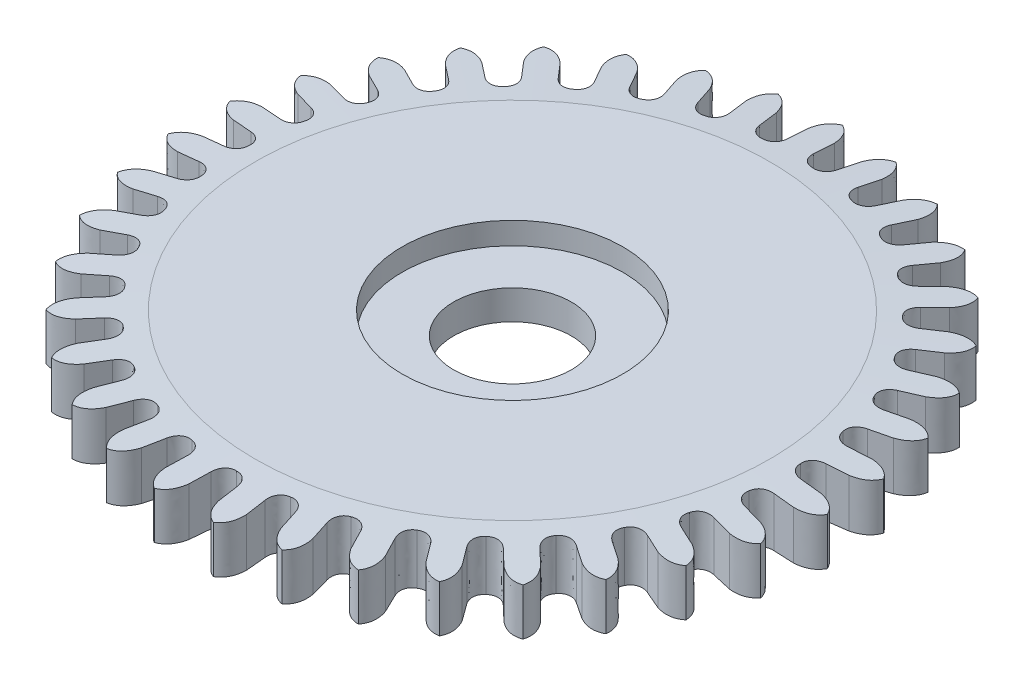
from build123d import *

# Parameters (mm, degrees)
SKETCH1_R                   = 4.485
BOSS_EXTRUDE1_DEPTH         = 0.7
CHAMFER1_SIZE               = 0.0614
CHAMFER1_SIZE2              = 0.985
SKETCH2_OUTSIDE_W           = 13.51
SKETCH2_OUTSIDE_H           = 13.51
CUT_EXTRUDE1_35_TEETH_DEPTH = 0.7
CUT_EXTRUDE2_REACH          = 8.378
SKETCH3_R                   = 0.8
SKETCH4_R                   = 1.5
CUT_EXTRUDE3_DEPTH          = 0.3


with BuildPart() as part:
    # Sketch1 → Boss-Extrude1 (new body)
    with BuildSketch(Plane(origin=(0, 0, 0), x_dir=(1, 0, 0), z_dir=(0, 1, 0))):
        with Locations(Location((0, 0, 0), (0, 0, 270))):
            Circle(SKETCH1_R)
    extrude(amount=BOSS_EXTRUDE1_DEPTH)

    # Chamfer1
    chamfer1_edges = [part.edges().sort_by_distance(p)[0] for p in [
        (0, 0.7, -4.485),
    ]]
    chamfer1_side = [part.faces().sort_by_distance(p)[0] for p in [
        (0, 0.35, -4.485),
    ]]
    chamfer(chamfer1_edges, length=CHAMFER1_SIZE, length2=CHAMFER1_SIZE2, reference=chamfer1_side[0])

    # Sketch2 outside → Cut-Extrude1 (35 teeth) (cut)
    with BuildSketch(Plane(origin=(0, 0, 0), x_dir=(1, 0, 0), z_dir=(0, 1, 0))):
        Rectangle(SKETCH2_OUTSIDE_W, SKETCH2_OUTSIDE_H)
        with BuildLine():
            Line((0.176, 4.199313396), (0.176, 3.919050012))
            add(Edge.make_bspline(
                [(0.176, 3.919050012), (0.17522517, 3.83644485), (0.222147531, 3.741303062), (0.336147408, 3.734903602)],
                knots=[0, 0, 0, 0, 1, 1, 1, 1], degree=3))
            add(Edge.make_bspline(
                [(0.526601793, 3.88749528), (0.51261445, 3.806079265), (0.449457929, 3.720844756), (0.336147408, 3.734903602)],
                knots=[0, 0, 0, 0, 1, 1, 1, 1], degree=3))
            Line((0.526601793, 3.88749528), (0.576644753, 4.163254716))
            add(Edge.make_bspline(
                [(0.800827673, 4.412924204), (0.637500689, 4.367124725), (0.576644753, 4.163254716)],
                knots=[0, 0, 0, 1, 1, 1], degree=2))
            add(Edge.make_bspline(
                [(0.800827673, 4.412924204), (0.937647307, 4.312656144), (0.922987968, 4.100402689)],
                knots=[0, 0, 0, 1, 1, 1], degree=2))
            Line((0.922987968, 4.100402689), (0.872945008, 3.824643253))
            add(Edge.make_bspline(
                [(0.872945008, 3.824643253), (0.857432909, 3.743503941), (0.886612986, 3.64151281), (0.997638171, 3.614860728)],
                knots=[0, 0, 0, 0, 1, 1, 1, 1], degree=3))
            add(Edge.make_bspline(
                [(1.212278171, 3.73099325), (1.18397822, 3.653383161), (1.106617441, 3.580795438), (0.997638171, 3.614860728)],
                knots=[0, 0, 0, 0, 1, 1, 1, 1], degree=3))
            Line((1.212278171, 3.73099325), (1.310755669, 3.993385603))
            add(Edge.make_bspline(
                [(1.575916086, 4.199013394), (1.407036021, 4.18311309), (1.310755669, 3.993385603)],
                knots=[0, 0, 0, 1, 1, 1], degree=2))
            add(Edge.make_bspline(
                [(1.575916086, 4.199013394), (1.692633418, 4.075926594), (1.640310343, 3.869701665)],
                knots=[0, 0, 0, 1, 1, 1], degree=2))
            Line((1.640310343, 3.869701665), (1.541832846, 3.607309312))
            add(Edge.make_bspline(
                [(1.541832846, 3.607309312), (1.512082049, 3.530243735), (1.52258197, 3.424681339), (1.627064022, 3.378633255)],
                knots=[0, 0, 0, 0, 1, 1, 1, 1], degree=3))
            add(Edge.make_bspline(
                [(1.858990932, 3.454574028), (1.817287955, 3.383264317), (1.728209357, 3.325656409), (1.627064022, 3.378633255)],
                knots=[0, 0, 0, 0, 1, 1, 1, 1], degree=3))
            Line((1.858990932, 3.454574028), (2.002737819, 3.695165792))
            add(Edge.make_bspline(
                [(2.300353259, 3.850142838), (2.131348057, 3.864652759), (2.002737819, 3.695165792)],
                knots=[0, 0, 0, 1, 1, 1], degree=2))
            add(Edge.make_bspline(
                [(2.300353259, 3.850142838), (2.393216899, 3.70819341), (2.304911794, 3.514625246)],
                knots=[0, 0, 0, 1, 1, 1], degree=2))
            Line((2.304911794, 3.514625246), (2.161164907, 3.274033482))
            add(Edge.make_bspline(
                [(2.161164907, 3.274033482), (2.118131628, 3.20351859), (2.109613917, 3.097777792), (2.204194696, 3.033813729)],
                knots=[0, 0, 0, 0, 1, 1, 1, 1], degree=3))
            add(Edge.make_bspline(
                [(2.445954194, 3.067121954), (2.392188561, 3.004404573), (2.294255204, 2.963628045), (2.204194696, 3.033813729)],
                knots=[0, 0, 0, 0, 1, 1, 1, 1], degree=3))
            Line((2.445954194, 3.067121954), (2.630350328, 3.278180311))
            add(Edge.make_bspline(
                [(2.950855185, 3.377525524), (2.787156813, 3.421979309), (2.630350328, 3.278180311)],
                knots=[0, 0, 0, 1, 1, 1], degree=2))
            add(Edge.make_bspline(
                [(2.950855185, 3.377525524), (3.016880419, 3.221275838), (2.895431484, 3.04658588)],
                knots=[0, 0, 0, 1, 1, 1], degree=2))
            Line((2.895431484, 3.04658588), (2.71103535, 2.835527522))
            add(Edge.make_bspline(
                [(2.71103535, 2.835527522), (2.656102713, 2.773829722), (2.628841137, 2.671309119), (2.710480739, 2.591484934)],
                knots=[0, 0, 0, 0, 1, 1, 1, 1], degree=3))
            add(Edge.make_bspline(
                [(2.954302476, 2.581090057), (2.890202258, 2.528980794), (2.7865618, 2.506346238), (2.710480739, 2.591484934)],
                knots=[0, 0, 0, 0, 1, 1, 1, 1], degree=3))
            Line((2.954302476, 2.581090057), (3.173421213, 2.755831418))
            add(Edge.make_bspline(
                [(3.506514198, 2.796351761), (3.353384056, 2.869320627), (3.173421213, 2.755831418)],
                knots=[0, 0, 0, 1, 1, 1], degree=2))
            add(Edge.make_bspline(
                [(3.506514198, 2.796351761), (3.543578921, 2.630823811), (3.392889623, 2.480626736)],
                knots=[0, 0, 0, 1, 1, 1], degree=2))
            Line((3.392889623, 2.480626736), (3.173770886, 2.305885375))
            add(Edge.make_bspline(
                [(3.173770886, 2.305885375), (3.108704471, 2.254987685), (3.06357524, 2.158982372), (3.129649701, 2.06586368)],
                knots=[0, 0, 0, 0, 1, 1, 1, 1], degree=3))
            add(Edge.make_bspline(
                [(3.367697045, 2.012099801), (3.295322476, 1.972273492), (3.189306007, 1.968508401), (3.129649701, 2.06586368)],
                knots=[0, 0, 0, 0, 1, 1, 1, 1], degree=3))
            Line((3.367697045, 2.012099801), (3.614495729, 2.144907836))
            add(Edge.make_bspline(
                [(3.949470959, 2.125300951), (3.811830776, 2.22443962), (3.614495729, 2.144907836)],
                knots=[0, 0, 0, 1, 1, 1], degree=2))
            add(Edge.make_bspline(
                [(3.949470959, 2.125300951), (3.95638388, 1.955814941), (3.781297498, 1.834938209)],
                knots=[0, 0, 0, 1, 1, 1], degree=2))
            Line((3.781297498, 1.834938209), (3.534498815, 1.702130174))
            add(Edge.make_bspline(
                [(3.534498815, 1.702130174), (3.46138991, 1.663668488), (3.399843513, 1.577264155), (3.448229147, 1.473843869)],
                knots=[0, 0, 0, 0, 1, 1, 1, 1], degree=3))
            add(Edge.make_bspline(
                [(3.672851061, 1.378439003), (3.594528319, 1.352175697), (3.489543295, 1.367401084), (3.448229147, 1.473843869)],
                knots=[0, 0, 0, 0, 1, 1, 1, 1], degree=3))
            Line((3.672851061, 1.378439003), (3.939397378, 1.465045151))
            add(Edge.make_bspline(
                [(4.265488474, 1.385941219), (4.147762119, 1.508063294), (3.939397378, 1.465045151)],
                knots=[0, 0, 0, 1, 1, 1], degree=2))
            add(Edge.make_bspline(
                [(4.265488474, 1.385941219), (4.242027406, 1.21794457), (4.04817136, 1.130273257)],
                knots=[0, 0, 0, 1, 1, 1], degree=2))
            Line((4.04817136, 1.130273257), (3.781625043, 1.043667109))
            add(Edge.make_bspline(
                [(3.781625043, 1.043667109), (3.70282343, 1.018877617), (3.626838019, 0.944851371), (3.655979671, 0.834453502)],
                knots=[0, 0, 0, 0, 1, 1, 1, 1], degree=3))
            add(Edge.make_bspline(
                [(3.859956621, 0.70047404), (3.778203063, 0.688617862), (3.67762379, 0.722344371), (3.655979671, 0.834453502)],
                knots=[0, 0, 0, 0, 1, 1, 1, 1], degree=3))
            Line((3.859956621, 0.70047404), (4.137683555, 0.738094709))
            add(Edge.make_bspline(
                [(4.44440968, 0.602036197), (4.350380974, 0.743216572), (4.137683555, 0.738094709)],
                knots=[0, 0, 0, 1, 1, 1], degree=2))
            add(Edge.make_bspline(
                [(4.44440968, 0.602036197), (4.391328681, 0.440928459), (4.184933664, 0.389280393)],
                knots=[0, 0, 0, 1, 1, 1], degree=2))
            Line((4.184933664, 0.389280393), (3.907206731, 0.351659724))
            add(Edge.make_bspline(
                [(3.907206731, 0.351659724), (3.825245157, 0.34133918), (3.737262967, 0.282070286), (3.746224, 0.168243114)],
                knots=[0, 0, 0, 0, 1, 1, 1, 1], degree=3))
            add(Edge.make_bspline(
                [(3.923, -4.734e-06), (3.840443253, 0.002927283), (3.747502431, 0.054070916), (3.746224, 0.168243114)],
                knots=[0, 0, 0, 0, 1, 1, 1, 1], degree=3))
            Line((3.923, -4.734e-06), (4.202981177, -0.012578703))
            add(Edge.make_bspline(
                [(4.480483902, -0.201218764), (4.413175005, -0.045517742), (4.202981177, -0.012578703)],
                knots=[0, 0, 0, 1, 1, 1], degree=2))
            add(Edge.make_bspline(
                [(4.480483902, -0.201218764), (4.399489039, -0.350259456), (4.187188757, -0.364224263)],
                knots=[0, 0, 0, 1, 1, 1], degree=2))
            Line((4.187188757, -0.364224263), (3.90720758, -0.351650294))
            add(Edge.make_bspline(
                [(3.90720758, -0.351650294), (3.824720358, -0.347170178), (3.727569208, -0.38977677), (3.716061607, -0.503374747)],
                knots=[0, 0, 0, 0, 1, 1, 1, 1], degree=3))
            add(Edge.make_bspline(
                [(3.859954931, -0.700483356), (3.779248437, -0.682857382), (3.69693326, -0.615940423), (3.716061607, -0.503374747)],
                knots=[0, 0, 0, 0, 1, 1, 1, 1], degree=3))
            Line((3.859954931, -0.700483356), (4.133191526, -0.762847826))
            add(Edge.make_bspline(
                [(4.372551685, -0.998006389), (4.33412596, -0.832789078), (4.133191526, -0.762847826)],
                knots=[0, 0, 0, 1, 1, 1], degree=2))
            add(Edge.make_bspline(
                [(4.372551685, -0.998006389), (4.266246199, -1.130189744), (4.054864158, -1.106022451)],
                knots=[0, 0, 0, 1, 1, 1], degree=2))
            Line((4.054864158, -1.106022451), (3.781627562, -1.043657982))
            add(Edge.make_bspline(
                [(3.781627562, -1.043657982), (3.701265899, -1.024521201), (3.598068307, -1.04909608), (3.566461936, -1.158813729)],
                knots=[0, 0, 0, 0, 1, 1, 1, 1], degree=3))
            add(Edge.make_bspline(
                [(3.672847734, -1.378447867), (3.596585466, -1.346694448), (3.527541612, -1.26615493), (3.566461936, -1.158813729)],
                knots=[0, 0, 0, 0, 1, 1, 1, 1], degree=3))
            Line((3.672847734, -1.378447867), (3.930557699, -1.488598392))
            add(Edge.make_bspline(
                [(4.124082059, -1.762717266), (4.115774541, -1.593293888), (3.930557699, -1.488598392)],
                knots=[0, 0, 0, 1, 1, 1], degree=2))
            add(Edge.make_bspline(
                [(4.124082059, -1.762717266), (3.995882696, -1.873794804), (3.792212888, -1.812272168)],
                knots=[0, 0, 0, 1, 1, 1], degree=2))
            Line((3.792212888, -1.812272168), (3.534502923, -1.702121643))
            add(Edge.make_bspline(
                [(3.534502923, -1.702121643), (3.458849709, -1.668943269), (3.352922531, -1.674696579), (3.302233244, -1.777007484)],
                knots=[0, 0, 0, 0, 1, 1, 1, 1], degree=3))
            add(Edge.make_bspline(
                [(3.367692189, -2.012107929), (3.298325279, -1.967247647), (3.244771874, -1.875674176), (3.302233244, -1.777007484)],
                knots=[0, 0, 0, 0, 1, 1, 1, 1], degree=3))
            Line((3.367692189, -2.012107929), (3.601592513, -2.166504181))
            add(Edge.make_bspline(
                [(3.743061042, -2.470772961), (3.765138742, -2.302588922), (3.601592513, -2.166504181)],
                knots=[0, 0, 0, 1, 1, 1], degree=2))
            add(Edge.make_bspline(
                [(3.743061042, -2.470772961), (3.597088236, -2.557174557), (3.407676776, -2.460273967)],
                knots=[0, 0, 0, 1, 1, 1], degree=2))
            Line((3.407676776, -2.460273967), (3.173776452, -2.305877715))
            add(Edge.make_bspline(
                [(3.173776452, -2.305877715), (3.105263244, -2.259724128), (3.000011066, -2.246470951), (2.931868059, -2.338086757)],
                knots=[0, 0, 0, 0, 1, 1, 1, 1], degree=3))
            add(Edge.make_bspline(
                [(2.954296246, -2.581097187), (2.894054204, -2.524571888), (2.857712499, -2.424907711), (2.931868059, -2.338086757)],
                knots=[0, 0, 0, 0, 1, 1, 1, 1], degree=3))
            Line((2.954296246, -2.581097187), (3.156869181, -2.774776743))
            add(Edge.make_bspline(
                [(3.241734963, -3.09941598), (3.293488285, -2.937876853), (3.156869181, -2.774776743)],
                knots=[0, 0, 0, 1, 1, 1], degree=2))
            add(Edge.make_bspline(
                [(3.241734963, -3.09941598), (3.0826804, -3.158364615), (2.913615128, -3.029200535)],
                knots=[0, 0, 0, 1, 1, 1], degree=2))
            Line((2.913615128, -3.029200535), (2.711042194, -2.835520979))
            add(Edge.make_bspline(
                [(2.711042194, -2.835520979), (2.651871063, -2.777875594), (2.550676776, -2.746041899), (2.467270222, -2.824017998)],
                knots=[0, 0, 0, 0, 1, 1, 1, 1], degree=3))
            add(Edge.make_bspline(
                [(2.445946791, -3.067127857), (2.396765845, -3.000754311), (2.378803892, -2.896202716), (2.467270222, -2.824017998)],
                knots=[0, 0, 0, 0, 1, 1, 1, 1], degree=3))
            Line((2.445946791, -3.067127857), (2.610681475, -3.293865698))
            add(Edge.make_bspline(
                [(2.636216856, -3.628441219), (2.715982406, -3.478739005), (2.610681475, -3.293865698)],
                knots=[0, 0, 0, 1, 1, 1], degree=2))
            add(Edge.make_bspline(
                [(2.636216856, -3.628441219), (2.469192679, -3.658042236), (2.325907493, -3.500766107)],
                knots=[0, 0, 0, 1, 1, 1], degree=2))
            Line((2.325907493, -3.500766107), (2.161172809, -3.274028266))
            add(Edge.make_bspline(
                [(2.161172809, -3.274028266), (2.113245563, -3.206743853), (2.019361637, -3.157352801), (1.92337229, -3.219182976)],
                knots=[0, 0, 0, 0, 1, 1, 1, 1], degree=3))
            add(Edge.make_bspline(
                [(1.858982594, -3.454578515), (1.82244346, -3.380490021), (1.823438571, -3.274411383), (1.92337229, -3.219182976)],
                knots=[0, 0, 0, 0, 1, 1, 1, 1], degree=3))
            Line((1.858982594, -3.454578515), (1.980584319, -3.707087098))
            add(Edge.make_bspline(
                [(1.945968569, -4.040845371), (2.051182617, -3.907791622), (1.980584319, -3.707087098)],
                knots=[0, 0, 0, 1, 1, 1], degree=2))
            add(Edge.make_bspline(
                [(1.945968569, -4.040845371), (1.776343074, -4.04014737), (1.663443277, -3.859814175)],
                knots=[0, 0, 0, 1, 1, 1], degree=2))
            Line((1.663443277, -3.859814175), (1.541841552, -3.607305591))
            add(Edge.make_bspline(
                [(1.541841552, -3.607305591), (1.506698613, -3.532544726), (1.423142553, -3.467183786), (1.31765559, -3.510880765)],
                knots=[0, 0, 0, 0, 1, 1, 1, 1], degree=3))
            add(Edge.make_bspline(
                [(1.212269166, -3.730996176), (1.189546243, -3.651574001), (1.209466434, -3.547377774), (1.31765559, -3.510880765)],
                knots=[0, 0, 0, 0, 1, 1, 1, 1], degree=3))
            Line((1.212269166, -3.730996176), (1.286829553, -4.001159669))
            add(Edge.make_bspline(
                [(1.193175252, -4.323373429), (1.32045613, -4.211244602), (1.286829553, -4.001159669)],
                knots=[0, 0, 0, 1, 1, 1], degree=2))
            add(Edge.make_bspline(
                [(1.193175252, -4.323373429), (1.026400341, -4.292398843), (0.947514626, -4.094804639)],
                knots=[0, 0, 0, 1, 1, 1], degree=2))
            Line((0.947514626, -4.094804639), (0.872954239, -3.824641146))
            add(Edge.make_bspline(
                [(0.872954239, -3.824641146), (0.85172513, -3.744806704), (0.781182496, -3.665576631), (0.669588355, -3.689735957)],
                knots=[0, 0, 0, 0, 1, 1, 1, 1], degree=3))
            add(Edge.make_bspline(
                [(0.52659241, -3.887496551), (0.51841603, -3.805293388), (0.556621051, -3.706328525), (0.669588355, -3.689735957)],
                knots=[0, 0, 0, 0, 1, 1, 1, 1], degree=3))
            Line((0.52659241, -3.887496551), (0.551715026, -4.166631677))
            add(Edge.make_bspline(
                [(0.4020323, -4.466944707), (0.547289098, -4.379344715), (0.551715026, -4.166631677)],
                knots=[0, 0, 0, 1, 1, 1], degree=2))
            add(Edge.make_bspline(
                [(0.4020323, -4.466944707), (0.243468257, -4.406689086), (0.201132075, -4.198184713)],
                knots=[0, 0, 0, 1, 1, 1], degree=2))
            Line((0.201132075, -4.198184713), (0.176009459, -3.919049588))
            add(Edge.make_bspline(
                [(0.176009459, -3.919049588), (0.1693765, -3.836707514), (0.114114591, -3.746154827), (0, -3.75)],
                knots=[0, 0, 0, 0, 1, 1, 1, 1], degree=3))
            add(Edge.make_bspline(
                [(-0.176009459, -3.919049588), (-0.1693765, -3.836707514), (-0.114114591, -3.746154827), (0, -3.75)],
                knots=[0, 0, 0, 0, 1, 1, 1, 1], degree=3))
            Line((-0.176009459, -3.919049588), (-0.201132075, -4.198184713))
            add(Edge.make_bspline(
                [(-0.4020323, -4.466944707), (-0.243468257, -4.406689086), (-0.201132075, -4.198184713)],
                knots=[0, 0, 0, 1, 1, 1], degree=2))
            add(Edge.make_bspline(
                [(-0.4020323, -4.466944707), (-0.547289098, -4.379344715), (-0.551715026, -4.166631677)],
                knots=[0, 0, 0, 1, 1, 1], degree=2))
            Line((-0.551715026, -4.166631677), (-0.52659241, -3.887496551))
            add(Edge.make_bspline(
                [(-0.52659241, -3.887496551), (-0.51841603, -3.805293388), (-0.556621051, -3.706328525), (-0.669588355, -3.689735957)],
                knots=[0, 0, 0, 0, 1, 1, 1, 1], degree=3))
            add(Edge.make_bspline(
                [(-0.872954239, -3.824641146), (-0.85172513, -3.744806704), (-0.781182496, -3.665576631), (-0.669588355, -3.689735957)],
                knots=[0, 0, 0, 0, 1, 1, 1, 1], degree=3))
            Line((-0.872954239, -3.824641146), (-0.947514626, -4.094804639))
            add(Edge.make_bspline(
                [(-1.193175252, -4.323373429), (-1.026400341, -4.292398843), (-0.947514626, -4.094804639)],
                knots=[0, 0, 0, 1, 1, 1], degree=2))
            add(Edge.make_bspline(
                [(-1.193175252, -4.323373429), (-1.32045613, -4.211244602), (-1.286829553, -4.001159669)],
                knots=[0, 0, 0, 1, 1, 1], degree=2))
            Line((-1.286829553, -4.001159669), (-1.212269166, -3.730996176))
            add(Edge.make_bspline(
                [(-1.212269166, -3.730996176), (-1.189546243, -3.651574001), (-1.209466434, -3.547377774), (-1.31765559, -3.510880765)],
                knots=[0, 0, 0, 0, 1, 1, 1, 1], degree=3))
            add(Edge.make_bspline(
                [(-1.541841552, -3.607305591), (-1.506698613, -3.532544726), (-1.423142553, -3.467183786), (-1.31765559, -3.510880765)],
                knots=[0, 0, 0, 0, 1, 1, 1, 1], degree=3))
            Line((-1.541841552, -3.607305591), (-1.663443277, -3.859814175))
            add(Edge.make_bspline(
                [(-1.945968569, -4.040845371), (-1.776343074, -4.04014737), (-1.663443277, -3.859814175)],
                knots=[0, 0, 0, 1, 1, 1], degree=2))
            add(Edge.make_bspline(
                [(-1.945968569, -4.040845371), (-2.051182617, -3.907791622), (-1.980584319, -3.707087098)],
                knots=[0, 0, 0, 1, 1, 1], degree=2))
            Line((-1.980584319, -3.707087098), (-1.858982594, -3.454578515))
            add(Edge.make_bspline(
                [(-1.858982594, -3.454578515), (-1.82244346, -3.380490021), (-1.823438571, -3.274411383), (-1.92337229, -3.219182976)],
                knots=[0, 0, 0, 0, 1, 1, 1, 1], degree=3))
            add(Edge.make_bspline(
                [(-2.161172809, -3.274028266), (-2.113245563, -3.206743853), (-2.019361637, -3.157352801), (-1.92337229, -3.219182976)],
                knots=[0, 0, 0, 0, 1, 1, 1, 1], degree=3))
            Line((-2.161172809, -3.274028266), (-2.325907493, -3.500766107))
            add(Edge.make_bspline(
                [(-2.636216856, -3.628441219), (-2.469192679, -3.658042236), (-2.325907493, -3.500766107)],
                knots=[0, 0, 0, 1, 1, 1], degree=2))
            add(Edge.make_bspline(
                [(-2.636216856, -3.628441219), (-2.715982406, -3.478739005), (-2.610681475, -3.293865698)],
                knots=[0, 0, 0, 1, 1, 1], degree=2))
            Line((-2.610681475, -3.293865698), (-2.445946791, -3.067127857))
            add(Edge.make_bspline(
                [(-2.445946791, -3.067127857), (-2.396765845, -3.000754311), (-2.378803892, -2.896202716), (-2.467270222, -2.824017998)],
                knots=[0, 0, 0, 0, 1, 1, 1, 1], degree=3))
            add(Edge.make_bspline(
                [(-2.711042194, -2.835520979), (-2.651871063, -2.777875594), (-2.550676776, -2.746041899), (-2.467270222, -2.824017998)],
                knots=[0, 0, 0, 0, 1, 1, 1, 1], degree=3))
            Line((-2.711042194, -2.835520979), (-2.913615128, -3.029200535))
            add(Edge.make_bspline(
                [(-3.241734963, -3.09941598), (-3.0826804, -3.158364615), (-2.913615128, -3.029200535)],
                knots=[0, 0, 0, 1, 1, 1], degree=2))
            add(Edge.make_bspline(
                [(-3.241734963, -3.09941598), (-3.293488285, -2.937876853), (-3.156869181, -2.774776743)],
                knots=[0, 0, 0, 1, 1, 1], degree=2))
            Line((-3.156869181, -2.774776743), (-2.954296246, -2.581097187))
            add(Edge.make_bspline(
                [(-2.954296246, -2.581097187), (-2.894054204, -2.524571888), (-2.857712499, -2.424907711), (-2.931868059, -2.338086757)],
                knots=[0, 0, 0, 0, 1, 1, 1, 1], degree=3))
            add(Edge.make_bspline(
                [(-3.173776452, -2.305877715), (-3.105263244, -2.259724128), (-3.000011066, -2.246470951), (-2.931868059, -2.338086757)],
                knots=[0, 0, 0, 0, 1, 1, 1, 1], degree=3))
            Line((-3.173776452, -2.305877715), (-3.407676776, -2.460273967))
            add(Edge.make_bspline(
                [(-3.743061042, -2.470772961), (-3.597088236, -2.557174557), (-3.407676776, -2.460273967)],
                knots=[0, 0, 0, 1, 1, 1], degree=2))
            add(Edge.make_bspline(
                [(-3.743061042, -2.470772961), (-3.765138742, -2.302588922), (-3.601592513, -2.166504181)],
                knots=[0, 0, 0, 1, 1, 1], degree=2))
            Line((-3.601592513, -2.166504181), (-3.367692189, -2.012107929))
            add(Edge.make_bspline(
                [(-3.367692189, -2.012107929), (-3.298325279, -1.967247647), (-3.244771874, -1.875674176), (-3.302233244, -1.777007484)],
                knots=[0, 0, 0, 0, 1, 1, 1, 1], degree=3))
            add(Edge.make_bspline(
                [(-3.534502923, -1.702121643), (-3.458849709, -1.668943269), (-3.352922531, -1.674696579), (-3.302233244, -1.777007484)],
                knots=[0, 0, 0, 0, 1, 1, 1, 1], degree=3))
            Line((-3.534502923, -1.702121643), (-3.792212888, -1.812272168))
            add(Edge.make_bspline(
                [(-4.124082059, -1.762717266), (-3.995882696, -1.873794804), (-3.792212888, -1.812272168)],
                knots=[0, 0, 0, 1, 1, 1], degree=2))
            add(Edge.make_bspline(
                [(-4.124082059, -1.762717266), (-4.115774541, -1.593293888), (-3.930557699, -1.488598392)],
                knots=[0, 0, 0, 1, 1, 1], degree=2))
            Line((-3.930557699, -1.488598392), (-3.672847734, -1.378447867))
            add(Edge.make_bspline(
                [(-3.672847734, -1.378447867), (-3.596585466, -1.346694448), (-3.527541612, -1.26615493), (-3.566461936, -1.158813729)],
                knots=[0, 0, 0, 0, 1, 1, 1, 1], degree=3))
            add(Edge.make_bspline(
                [(-3.781627562, -1.043657982), (-3.701265899, -1.024521201), (-3.598068307, -1.04909608), (-3.566461936, -1.158813729)],
                knots=[0, 0, 0, 0, 1, 1, 1, 1], degree=3))
            Line((-3.781627562, -1.043657982), (-4.054864158, -1.106022451))
            add(Edge.make_bspline(
                [(-4.372551685, -0.998006389), (-4.266246199, -1.130189744), (-4.054864158, -1.106022451)],
                knots=[0, 0, 0, 1, 1, 1], degree=2))
            add(Edge.make_bspline(
                [(-4.372551685, -0.998006389), (-4.33412596, -0.832789078), (-4.133191526, -0.762847826)],
                knots=[0, 0, 0, 1, 1, 1], degree=2))
            Line((-4.133191526, -0.762847826), (-3.859954931, -0.700483356))
            add(Edge.make_bspline(
                [(-3.859954931, -0.700483356), (-3.779248437, -0.682857382), (-3.69693326, -0.615940423), (-3.716061607, -0.503374747)],
                knots=[0, 0, 0, 0, 1, 1, 1, 1], degree=3))
            add(Edge.make_bspline(
                [(-3.90720758, -0.351650294), (-3.824720358, -0.347170178), (-3.727569208, -0.38977677), (-3.716061607, -0.503374747)],
                knots=[0, 0, 0, 0, 1, 1, 1, 1], degree=3))
            Line((-3.90720758, -0.351650294), (-4.187188757, -0.364224263))
            add(Edge.make_bspline(
                [(-4.480483902, -0.201218764), (-4.399489039, -0.350259456), (-4.187188757, -0.364224263)],
                knots=[0, 0, 0, 1, 1, 1], degree=2))
            add(Edge.make_bspline(
                [(-4.480483902, -0.201218764), (-4.413175005, -0.045517742), (-4.202981177, -0.012578703)],
                knots=[0, 0, 0, 1, 1, 1], degree=2))
            Line((-4.202981177, -0.012578703), (-3.923, -4.734e-06))
            add(Edge.make_bspline(
                [(-3.923, -4.734e-06), (-3.840443253, 0.002927283), (-3.747502431, 0.054070916), (-3.746224, 0.168243114)],
                knots=[0, 0, 0, 0, 1, 1, 1, 1], degree=3))
            add(Edge.make_bspline(
                [(-3.907206731, 0.351659724), (-3.825245157, 0.34133918), (-3.737262967, 0.282070286), (-3.746224, 0.168243114)],
                knots=[0, 0, 0, 0, 1, 1, 1, 1], degree=3))
            Line((-3.907206731, 0.351659724), (-4.184933664, 0.389280393))
            add(Edge.make_bspline(
                [(-4.44440968, 0.602036197), (-4.391328681, 0.440928459), (-4.184933664, 0.389280393)],
                knots=[0, 0, 0, 1, 1, 1], degree=2))
            add(Edge.make_bspline(
                [(-4.44440968, 0.602036197), (-4.350380974, 0.743216572), (-4.137683555, 0.738094709)],
                knots=[0, 0, 0, 1, 1, 1], degree=2))
            Line((-4.137683555, 0.738094709), (-3.859956621, 0.70047404))
            add(Edge.make_bspline(
                [(-3.859956621, 0.70047404), (-3.778203063, 0.688617862), (-3.67762379, 0.722344371), (-3.655979671, 0.834453502)],
                knots=[0, 0, 0, 0, 1, 1, 1, 1], degree=3))
            add(Edge.make_bspline(
                [(-3.781625043, 1.043667109), (-3.70282343, 1.018877617), (-3.626838019, 0.944851371), (-3.655979671, 0.834453502)],
                knots=[0, 0, 0, 0, 1, 1, 1, 1], degree=3))
            Line((-3.781625043, 1.043667109), (-4.04817136, 1.130273257))
            add(Edge.make_bspline(
                [(-4.265488474, 1.385941219), (-4.242027406, 1.21794457), (-4.04817136, 1.130273257)],
                knots=[0, 0, 0, 1, 1, 1], degree=2))
            add(Edge.make_bspline(
                [(-4.265488474, 1.385941219), (-4.147762119, 1.508063294), (-3.939397378, 1.465045151)],
                knots=[0, 0, 0, 1, 1, 1], degree=2))
            Line((-3.939397378, 1.465045151), (-3.672851061, 1.378439003))
            add(Edge.make_bspline(
                [(-3.672851061, 1.378439003), (-3.594528319, 1.352175697), (-3.489543295, 1.367401084), (-3.448229147, 1.473843869)],
                knots=[0, 0, 0, 0, 1, 1, 1, 1], degree=3))
            add(Edge.make_bspline(
                [(-3.534498815, 1.702130174), (-3.46138991, 1.663668488), (-3.399843513, 1.577264155), (-3.448229147, 1.473843869)],
                knots=[0, 0, 0, 0, 1, 1, 1, 1], degree=3))
            Line((-3.534498815, 1.702130174), (-3.781297498, 1.834938209))
            add(Edge.make_bspline(
                [(-3.949470959, 2.125300951), (-3.95638388, 1.955814941), (-3.781297498, 1.834938209)],
                knots=[0, 0, 0, 1, 1, 1], degree=2))
            add(Edge.make_bspline(
                [(-3.949470959, 2.125300951), (-3.811830776, 2.22443962), (-3.614495729, 2.144907836)],
                knots=[0, 0, 0, 1, 1, 1], degree=2))
            Line((-3.614495729, 2.144907836), (-3.367697045, 2.012099801))
            add(Edge.make_bspline(
                [(-3.367697045, 2.012099801), (-3.295322476, 1.972273492), (-3.189306007, 1.968508401), (-3.129649701, 2.06586368)],
                knots=[0, 0, 0, 0, 1, 1, 1, 1], degree=3))
            add(Edge.make_bspline(
                [(-3.173770886, 2.305885375), (-3.108704471, 2.254987685), (-3.06357524, 2.158982372), (-3.129649701, 2.06586368)],
                knots=[0, 0, 0, 0, 1, 1, 1, 1], degree=3))
            Line((-3.173770886, 2.305885375), (-3.392889623, 2.480626736))
            add(Edge.make_bspline(
                [(-3.506514198, 2.796351761), (-3.543578921, 2.630823811), (-3.392889623, 2.480626736)],
                knots=[0, 0, 0, 1, 1, 1], degree=2))
            add(Edge.make_bspline(
                [(-3.506514198, 2.796351761), (-3.353384056, 2.869320627), (-3.173421213, 2.755831418)],
                knots=[0, 0, 0, 1, 1, 1], degree=2))
            Line((-3.173421213, 2.755831418), (-2.954302476, 2.581090057))
            add(Edge.make_bspline(
                [(-2.954302476, 2.581090057), (-2.890202258, 2.528980794), (-2.7865618, 2.506346238), (-2.710480739, 2.591484934)],
                knots=[0, 0, 0, 0, 1, 1, 1, 1], degree=3))
            add(Edge.make_bspline(
                [(-2.71103535, 2.835527522), (-2.656102713, 2.773829722), (-2.628841137, 2.671309119), (-2.710480739, 2.591484934)],
                knots=[0, 0, 0, 0, 1, 1, 1, 1], degree=3))
            Line((-2.71103535, 2.835527522), (-2.895431484, 3.04658588))
            add(Edge.make_bspline(
                [(-2.950855185, 3.377525524), (-3.016880419, 3.221275838), (-2.895431484, 3.04658588)],
                knots=[0, 0, 0, 1, 1, 1], degree=2))
            add(Edge.make_bspline(
                [(-2.950855185, 3.377525524), (-2.787156813, 3.421979309), (-2.630350328, 3.278180311)],
                knots=[0, 0, 0, 1, 1, 1], degree=2))
            Line((-2.630350328, 3.278180311), (-2.445954194, 3.067121954))
            add(Edge.make_bspline(
                [(-2.445954194, 3.067121954), (-2.392188561, 3.004404573), (-2.294255204, 2.963628045), (-2.204194696, 3.033813729)],
                knots=[0, 0, 0, 0, 1, 1, 1, 1], degree=3))
            add(Edge.make_bspline(
                [(-2.161164907, 3.274033482), (-2.118131628, 3.20351859), (-2.109613917, 3.097777792), (-2.204194696, 3.033813729)],
                knots=[0, 0, 0, 0, 1, 1, 1, 1], degree=3))
            Line((-2.161164907, 3.274033482), (-2.304911794, 3.514625246))
            add(Edge.make_bspline(
                [(-2.300353259, 3.850142838), (-2.393216899, 3.70819341), (-2.304911794, 3.514625246)],
                knots=[0, 0, 0, 1, 1, 1], degree=2))
            add(Edge.make_bspline(
                [(-2.300353259, 3.850142838), (-2.131348057, 3.864652759), (-2.002737819, 3.695165792)],
                knots=[0, 0, 0, 1, 1, 1], degree=2))
            Line((-2.002737819, 3.695165792), (-1.858990932, 3.454574028))
            add(Edge.make_bspline(
                [(-1.858990932, 3.454574028), (-1.817287955, 3.383264317), (-1.728209357, 3.325656409), (-1.627064022, 3.378633255)],
                knots=[0, 0, 0, 0, 1, 1, 1, 1], degree=3))
            add(Edge.make_bspline(
                [(-1.541832846, 3.607309312), (-1.512082049, 3.530243735), (-1.52258197, 3.424681339), (-1.627064022, 3.378633255)],
                knots=[0, 0, 0, 0, 1, 1, 1, 1], degree=3))
            Line((-1.541832846, 3.607309312), (-1.640310343, 3.869701665))
            add(Edge.make_bspline(
                [(-1.575916086, 4.199013394), (-1.692633418, 4.075926594), (-1.640310343, 3.869701665)],
                knots=[0, 0, 0, 1, 1, 1], degree=2))
            add(Edge.make_bspline(
                [(-1.575916086, 4.199013394), (-1.407036021, 4.18311309), (-1.310755669, 3.993385603)],
                knots=[0, 0, 0, 1, 1, 1], degree=2))
            Line((-1.310755669, 3.993385603), (-1.212278171, 3.73099325))
            add(Edge.make_bspline(
                [(-1.212278171, 3.73099325), (-1.18397822, 3.653383161), (-1.106617441, 3.580795438), (-0.997638171, 3.614860728)],
                knots=[0, 0, 0, 0, 1, 1, 1, 1], degree=3))
            add(Edge.make_bspline(
                [(-0.872945008, 3.824643253), (-0.857432909, 3.743503941), (-0.886612986, 3.64151281), (-0.997638171, 3.614860728)],
                knots=[0, 0, 0, 0, 1, 1, 1, 1], degree=3))
            Line((-0.872945008, 3.824643253), (-0.922987968, 4.100402689))
            add(Edge.make_bspline(
                [(-0.800827673, 4.412924204), (-0.937647307, 4.312656144), (-0.922987968, 4.100402689)],
                knots=[0, 0, 0, 1, 1, 1], degree=2))
            add(Edge.make_bspline(
                [(-0.800827673, 4.412924204), (-0.637500689, 4.367124725), (-0.576644753, 4.163254716)],
                knots=[0, 0, 0, 1, 1, 1], degree=2))
            Line((-0.576644753, 4.163254716), (-0.526601793, 3.88749528))
            add(Edge.make_bspline(
                [(-0.526601793, 3.88749528), (-0.51261445, 3.806079265), (-0.449457929, 3.720844756), (-0.336147408, 3.734903602)],
                knots=[0, 0, 0, 0, 1, 1, 1, 1], degree=3))
            add(Edge.make_bspline(
                [(-0.176, 3.919050012), (-0.17522517, 3.83644485), (-0.222147531, 3.741303062), (-0.336147408, 3.734903602)],
                knots=[0, 0, 0, 0, 1, 1, 1, 1], degree=3))
            Line((-0.176, 3.919050012), (-0.176, 4.199313396))
            add(Edge.make_bspline(
                [(0, 4.484999999), (-0.152524439, 4.410773377), (-0.176, 4.199313396)],
                knots=[0, 0, 0, 1, 1, 1], degree=2))
            add(Edge.make_bspline(
                [(0, 4.484999999), (0.152524439, 4.410773377), (0.176, 4.199313396)],
                knots=[0, 0, 0, 1, 1, 1], degree=2))
        make_face(mode=Mode.SUBTRACT)
    extrude(amount=CUT_EXTRUDE1_35_TEETH_DEPTH, mode=Mode.SUBTRACT)

    # Sketch3 → Cut-Extrude2 (cut, up to next)
    with BuildSketch(Plane(origin=(0, 0, 0), x_dir=(1, 0, 0), z_dir=(0, 1, 0)), mode=Mode.PRIVATE) as cut_extrude2_sk1:
        with Locations(Location((0, 0, 0), (0, 0, 270))):
            Circle(SKETCH3_R)
    cut_extrude2_tool1 = extrude(cut_extrude2_sk1.sketch, amount=CUT_EXTRUDE2_REACH, mode=Mode.PRIVATE) & part.part
    add(cut_extrude2_tool1.solids().sort_by_distance((0, 0, 0))[0], mode=Mode.SUBTRACT)

    # Sketch4 → Cut-Extrude3 (cut)
    with BuildSketch(Plane(origin=(0, 0.7, 0), x_dir=(1, 0, 0), z_dir=(0, 1, 0))):
        with Locations(Location((0, 0, 0), (0, 0, 270))):
            Circle(SKETCH4_R)
    extrude(amount=-CUT_EXTRUDE3_DEPTH, mode=Mode.SUBTRACT)


solid = part.part
